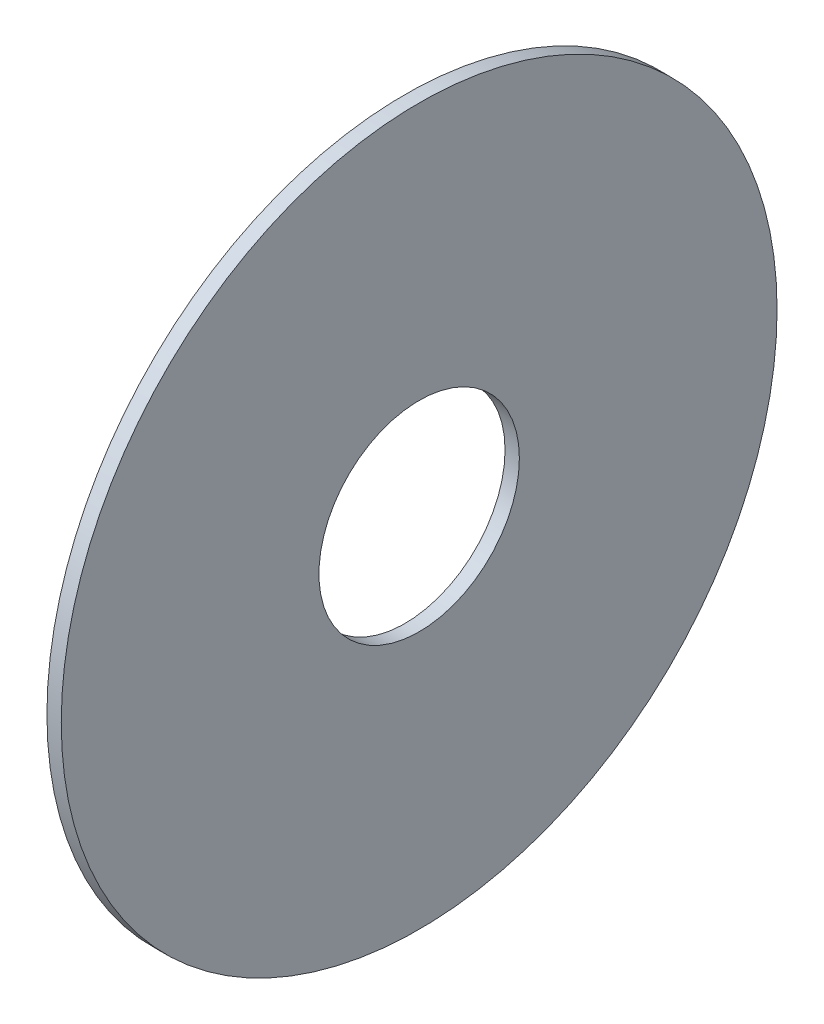
from build123d import *

# Parameters (mm, degrees)
SKETCH1_R           = 19.05
SKETCH1_R_2         = 5.334
BOSS_EXTRUDE2_DEPTH = 0.762


with BuildPart() as part:
    # Sketch1 → Boss-Extrude2 (new body)
    with BuildSketch(Plane(origin=(0, 0, 0), x_dir=(0, 0, -1), z_dir=(1, 0, 0))):
        Circle(SKETCH1_R)
        Circle(SKETCH1_R_2, mode=Mode.SUBTRACT)
    extrude(amount=BOSS_EXTRUDE2_DEPTH)


solid = part.part
